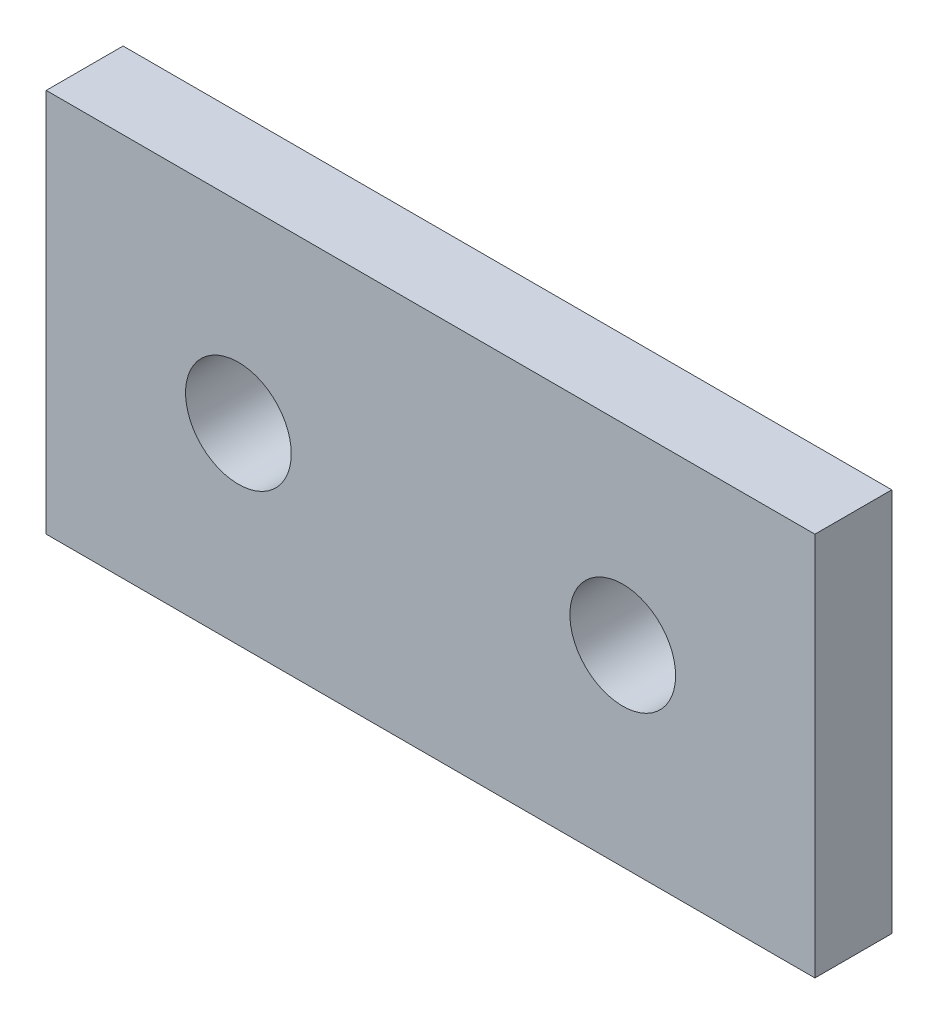
from build123d import *

# Parameters (mm, degrees)
SKETCH1_W           = 40
SKETCH1_H           = 20
SKETCH1_R           = 2.75
BOSS_EXTRUDE1_DEPTH = 2


with BuildPart() as part:
    # Sketch1 → Boss-Extrude1 (new body, symmetric)
    with BuildSketch(Plane.XY):
        Rectangle(SKETCH1_W, SKETCH1_H)
        with Locations((-10, 0)):
            Circle(SKETCH1_R, mode=Mode.SUBTRACT)
        with Locations((10, 0)):
            Circle(SKETCH1_R, mode=Mode.SUBTRACT)
    extrude(amount=BOSS_EXTRUDE1_DEPTH, both=True)


solid = part.part
